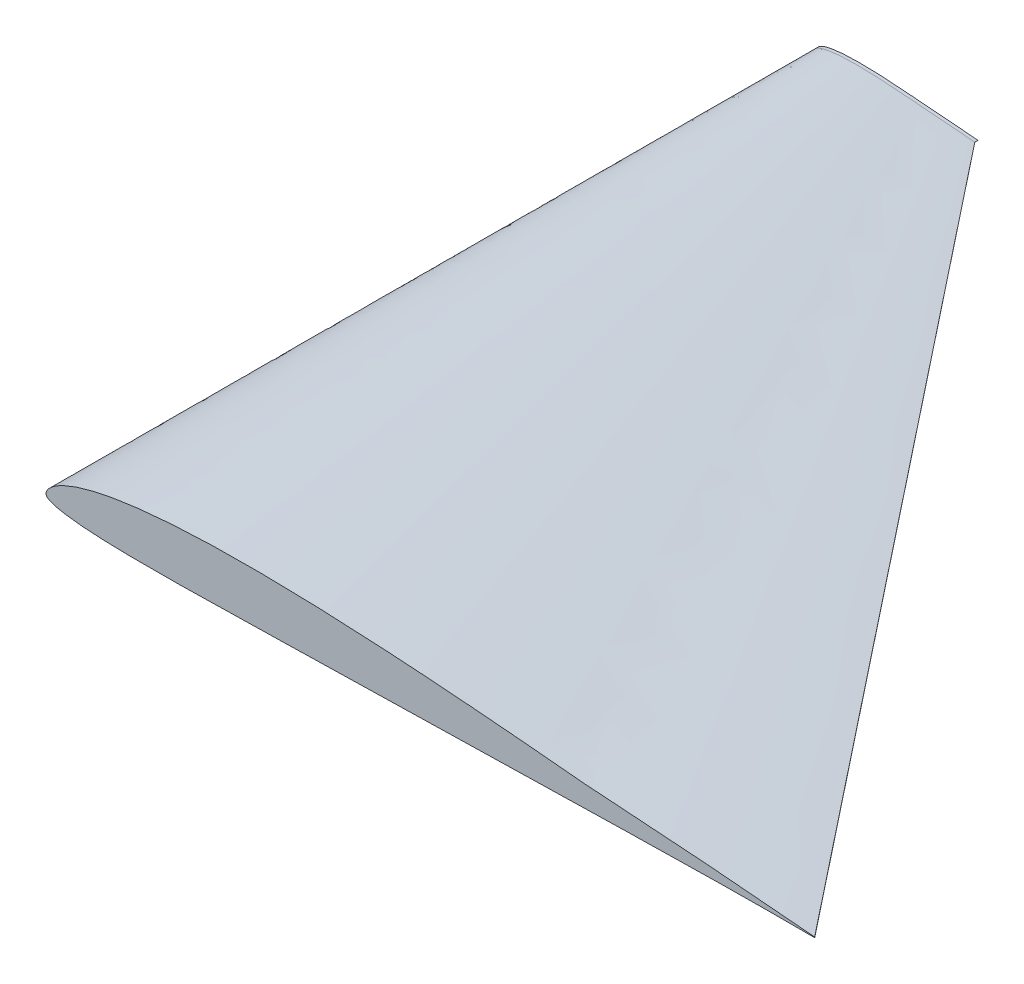
from build123d import *

# Parameters (mm, degrees)
BOSS_EXTRUDE1_DEPTH = 1.27


with BuildPart() as part:
    # Sketch2 → Boss-Extrude1 (new body, symmetric)
    with BuildSketch(Plane.XY):
        with BuildLine():
            Line((127, 0.053594), (127, -0.053594))
            add(Edge.make_bspline(
                [(127, 0.053594), (126.753194187, 0.0760877), (126.00456669, 0.144317059), (124.687918153, 0.26566799), (123.038030908, 0.409881649), (121.307814074, 0.562155781), (119.56263313, 0.715397667), (117.812451704, 0.862564502), (116.060214863, 1.009636724), (114.306556412, 1.15328943), (112.552387701, 1.2954065), (110.798143323, 1.434426003), (109.044365051, 1.569754719), (107.291127286, 1.704537205), (105.538591662, 1.83509141), (103.786392409, 1.964192438), (102.035125629, 2.09083844), (100.284111127, 2.213966217), (98.533897673, 2.336442107), (96.783942419, 2.455531649), (95.034673331, 2.572302888), (93.285592827, 2.687141326), (91.667333214, 2.791597652), (90.409246871, 2.86960854), (89.623239279, 2.921474225), (89.178221792, 2.944143026), (88.736217458, 2.991519492), (87.806500923, 3.077809397), (86.389824841, 3.21548482), (84.900074515, 3.35447567), (83.568446207, 3.477961158), (82.375283312, 3.587920635), (80.880163534, 3.723626147), (79.133561009, 3.880226285), (77.350706131, 4.036649252), (75.57251636, 4.189768369), (73.896258707, 4.331453772), (72.247372758, 4.468190396), (70.810741479, 4.584528401), (69.625039724, 4.678864068), (68.320779781, 4.781533777), (66.809591419, 4.897081839), (65.051660571, 5.027943928), (63.29489006, 5.154836731), (60.953639975, 5.317587866), (58.612649049, 5.470985337), (56.272130878, 5.614205871), (54.517155472, 5.715925242), (52.17781775, 5.84388823), (49.83871845, 5.959559707), (47.499751836, 6.061666427), (45.746142499, 6.131533932), (43.99292996, 6.19316573), (42.240233788, 6.246996168), (40.488296074, 6.292392907), (38.737205548, 6.329056298), (36.986991272, 6.355670586), (35.237667832, 6.37260324), (33.489390788, 6.378111917), (31.742631161, 6.371924362), (29.997598516, 6.353106175), (28.254705362, 6.321034192), (26.514212819, 6.273959582), (24.776789822, 6.210936383), (23.043308585, 6.130697271), (21.314341904, 6.031175464), (19.591301924, 5.911384312), (17.875349563, 5.768217119), (16.168057976, 5.600170111), (14.472222252, 5.403361178), (12.790310639, 5.17550056), (11.127244451, 4.911893185), (9.487723542, 4.607203654), (7.881002216, 4.255424938), (6.321671242, 3.849192622), (4.838377158, 3.3853758), (3.4861692, 2.868431212), (2.344289839, 2.326290026), (1.473834041, 1.805034205), (0.873330801, 1.3482402), (0.483486895, 0.969607531), (0.235533738, 0.65562371), (0.085352034, 0.388606743), (0.009278126, 0.159258483), (-0.008212661, -0.042739441), (0.035433453, -0.233172338), (0.160769969, -0.416078939), (0.381844651, -0.578881525), (0.702443674, -0.744483608), (1.173773308, -0.923146696), (1.873336967, -1.121921903), (2.863352071, -1.325051442), (4.13416469, -1.514401551), (5.608772302, -1.671307235), (7.196892742, -1.792063517), (8.842033522, -1.881526049), (10.518101058, -1.94501169), (12.213760951, -1.988134813), (13.923057968, -2.015603352), (15.642305988, -2.030559213), (17.369324492, -2.03524324), (19.102259281, -2.030376268), (20.840178662, -2.017661001), (22.581905241, -1.998654224), (24.327094149, -1.973870035), (26.075373333, -1.944918864), (27.827248085, -1.912478734), (29.582726999, -1.877605576), (31.342000464, -1.840019272), (33.105065172, -1.801905031), (34.872261178, -1.761818771), (36.643314641, -1.721008732), (39.010854937, -1.665986942), (41.381807413, -1.609827319), (43.75560561, -1.553814319), (45.538561311, -1.511849459), (47.323033301, -1.46955775), (49.109250939, -1.427647022), (50.897446959, -1.385341566), (52.686668924, -1.343543423), (54.475758497, -1.30172749), (56.263619605, -1.260128912), (58.050348911, -1.219185975), (59.835998699, -1.177618913), (61.620483593, -1.137195049), (63.403644196, -1.096671294), (65.185629967, -1.056824853), (66.966841129, -1.016671311), (68.474715573, -0.983169692), (70.232782952, -0.944255707), (71.967211638, -0.905142513), (73.938977171, -0.86146372), (75.655131362, -0.823379675), (77.377116294, -0.784663907), (79.116977386, -0.746124442), (80.674292865, -0.711626582), (82.037721658, -0.681571553), (83.189530456, -0.656499215), (84.514431826, -0.627441819), (86.036149029, -0.594655294), (87.442288836, -0.564185094), (88.395472904, -0.544103578), (88.857745192, -0.53403148), (89.250570862, -0.526534286), (90.047987318, -0.508966656), (91.345085306, -0.481934603), (93.049931567, -0.446327812), (94.810657831, -0.41008595), (96.570459821, -0.374659881), (98.329784851, -0.339179197), (100.089333738, -0.304693935), (101.849164273, -0.270047735), (103.609427245, -0.236629083), (105.36992798, -0.203795698), (107.130919286, -0.174231328), (109.479457843, -0.136894236), (111.828794682, -0.105060522), (114.178357376, -0.07832436), (115.941250848, -0.062296483), (117.704221306, -0.048903014), (119.467622017, -0.040031049), (121.230174814, -0.035574086), (122.981472146, -0.034856596), (124.653848233, -0.041755393), (125.989887143, -0.047834399), (126.749429154, -0.052165261), (127, -0.053594)],
                knots=[0, 0, 0, 0, 0.002900997, 0.008799492, 0.015477521, 0.022287594, 0.029131106, 0.035984573, 0.042846882, 0.049714298, 0.05658103, 0.063447841, 0.070313229, 0.077171168, 0.084031174, 0.090884627, 0.097737396, 0.104584409, 0.111431996, 0.118274877, 0.125116136, 0.131953905, 0.138793041, 0.144098463, 0.146708547, 0.148014316, 0.149313147, 0.151910856, 0.158944662, 0.165973894, 0.169425198, 0.174599098, 0.179999827, 0.186998484, 0.195126222, 0.200949457, 0.207890371, 0.214817866, 0.220316978, 0.224762114, 0.228741132, 0.235631413, 0.242503169, 0.249375779, 0.256249105, 0.269975124, 0.276837254, 0.283697593, 0.290552693, 0.304261607, 0.311111523, 0.317957829, 0.324804965, 0.331646618, 0.338483878, 0.345319338, 0.352148661, 0.358973535, 0.365797142, 0.372613328, 0.379420455, 0.386224885, 0.393018255, 0.399801226, 0.406575621, 0.413331117, 0.420072962, 0.426793048, 0.433486562, 0.440153627, 0.446776036, 0.453352888, 0.45986197, 0.466293612, 0.472602109, 0.478718386, 0.484476601, 0.489534097, 0.493495639, 0.496331131, 0.498346313, 0.499841011, 0.500999224, 0.501914653, 0.502649229, 0.503345398, 0.504157805, 0.50518516, 0.50652574, 0.508375842, 0.511073875, 0.515031357, 0.520196697, 0.526108615, 0.532386125, 0.538838474, 0.545393385, 0.552018993, 0.558693317, 0.565404176, 0.572144526, 0.578909155, 0.585689295, 0.592488493, 0.599298368, 0.606119897, 0.612956027, 0.619808707, 0.626672964, 0.633554162, 0.640451345, 0.647364459, 0.654290996, 0.668172424, 0.675125782, 0.68208558, 0.689048858, 0.69602005, 0.703000172, 0.70998671, 0.716969769, 0.723948347, 0.730920449, 0.737890086, 0.744856199, 0.751814362, 0.758768528, 0.765720713, 0.772669892, 0.776423534, 0.786305074, 0.792977667, 0.799509992, 0.806398719, 0.813139713, 0.819881191, 0.82463258, 0.829103409, 0.833367055, 0.84014514, 0.846920231, 0.849830697, 0.851305256, 0.85233271, 0.85442981, 0.86064179, 0.867519383, 0.874390494, 0.8812566, 0.888123181, 0.894988723, 0.901857217, 0.908727131, 0.915597457, 0.922468599, 0.929343575, 0.943092095, 0.949971604, 0.956848493, 0.963728748, 0.970608901, 0.977490477, 0.984360632, 0.991108924, 0.997066858, 1, 1, 1, 1], degree=3))
        make_face()
    extrude(amount=BOSS_EXTRUDE1_DEPTH, both=True)

    # Sketch3 → section 1 of loft4
    with BuildSketch(Plane.XY.offset(610.87), mode=Mode.PRIVATE) as loft4_s1:
        with BuildLine():
            Line((609.6, 0.2572512), (609.6, -0.2572512))
            add(Edge.make_bspline(
                [(609.6, 0.2572512), (608.415332097, 0.365220961), (604.821920112, 0.692721884), (598.502007136, 1.275206353), (590.58254836, 1.967431913), (582.277507556, 2.69834775), (573.900639024, 3.433908802), (565.499768181, 4.14030961), (557.08903134, 4.846256275), (548.671470775, 5.535789265), (540.251460963, 6.217951202), (531.831087952, 6.885244816), (523.412952246, 7.534822651), (514.997410973, 8.181778582), (506.585239979, 8.808438766), (498.174683562, 9.428123701), (489.768603017, 10.036024513), (481.363733408, 10.627037843), (472.962708832, 11.214922115), (464.562923613, 11.786551917), (456.166431988, 12.347053861), (447.770845571, 12.898278365), (440.003199426, 13.399668731), (433.96438498, 13.774120994), (430.191548537, 14.023076282), (428.055464604, 14.131886527), (425.933843798, 14.359293563), (421.47120443, 14.773485107), (414.671159239, 15.434327135), (407.520357673, 16.101483217), (401.128541792, 16.694213561), (395.401359899, 17.22201905), (388.224784964, 17.873405506), (379.841092841, 18.625086168), (371.28338943, 19.375916411), (362.748078527, 20.110888169), (354.702041793, 20.790978105), (346.78738924, 21.447313902), (339.891559101, 22.005736324), (334.200190675, 22.458547528), (327.939742949, 22.951362128), (320.686038813, 23.505992825), (312.247970741, 24.134130856), (303.815472288, 24.743216311), (292.577471879, 25.524421758), (281.340715435, 26.260729616), (270.106228216, 26.94818818), (261.682346264, 27.436441163), (250.453525202, 28.050663502), (239.225848559, 28.605886591), (227.998808811, 29.09599885), (219.581483994, 29.431362872), (211.166063809, 29.727195505), (202.753122181, 29.985581608), (194.343821157, 30.203485951), (185.938586629, 30.379470231), (177.537558104, 30.507218814), (169.140805594, 30.588495554), (160.749075784, 30.614937204), (152.364629575, 30.585236939), (143.988472876, 30.494909638), (135.622585739, 30.340964124), (127.268221532, 30.115005994), (118.928591145, 29.812494639), (110.60788121, 29.427346901), (102.308841137, 28.949642229), (94.038249233, 28.3746447), (85.801677902, 27.687442171), (77.606678285, 26.880816531), (69.466666809, 25.936133655), (61.393491068, 24.842402689), (53.410773367, 23.577087289), (45.541073, 22.114577537), (37.828810634, 20.426039702), (30.344021962, 18.476124586), (23.224210357, 16.249803841), (16.73361216, 13.768469819), (11.252591229, 11.166192123), (7.074403395, 8.664164182), (4.191987844, 6.471552962), (2.320737094, 4.654116149), (1.130561945, 3.146993807), (0.409689764, 1.865312365), (0.044535005, 0.764440717), (-0.039420771, -0.205149315), (0.170080572, -1.119227224), (0.77169585, -1.997178905), (1.832854324, -2.778631321), (3.371729637, -3.573521318), (5.634111878, -4.43110414), (8.992017444, -5.385225136), (13.744089942, -6.360246924), (19.84399051, -7.269127446), (26.92210705, -8.022274727), (34.545085162, -8.60190488), (42.441760907, -9.031325034), (50.486885076, -9.336056111), (58.626052563, -9.543047104), (66.830678248, -9.67489609), (75.083068743, -9.746684223), (83.37275756, -9.769167554), (91.690844547, -9.745806087), (100.032857577, -9.684772804), (108.393145156, -9.593540277), (116.770051914, -9.474576166), (125.161791998, -9.335610545), (133.570790806, -9.179897921), (141.997089596, -9.012506765), (150.441602227, -8.832092507), (158.904312825, -8.64914415), (167.386853653, -8.456730101), (175.887910278, -8.260841912), (187.252103698, -7.996737324), (198.632675581, -7.727171132), (210.026906928, -7.45830873), (218.585094291, -7.256877402), (227.150559846, -7.053877202), (235.724404509, -6.852705707), (244.307745405, -6.649639518), (252.896010837, -6.449008432), (261.483640787, -6.24829195), (270.065374104, -6.048618778), (278.641674775, -5.85209268), (287.212793757, -5.65257078), (295.778321245, -5.458536237), (304.337492142, -5.264022213), (312.891023844, -5.072759296), (321.44083742, -4.880022295), (328.678634748, -4.71921452), (337.117358168, -4.532427393), (345.442615864, -4.344684062), (354.907090423, -4.135025854), (363.144630539, -3.952222438), (371.410158212, -3.766386754), (379.761491454, -3.581397323), (387.236605751, -3.415807595), (393.781063961, -3.271543457), (399.309746187, -3.151196232), (405.669272764, -3.011720732), (412.973515337, -2.854345409), (419.722986413, -2.708088451), (424.298269937, -2.611697174), (426.517176923, -2.563351102), (428.402740136, -2.527364572), (432.230339127, -2.443039947), (438.456409466, -2.313286096), (446.639671523, -2.142373496), (455.091157591, -1.96841256), (463.538207143, -1.798367427), (471.982967287, -1.628060144), (480.428801943, -1.462530887), (488.87598851, -1.296229127), (497.325250778, -1.135819597), (505.775654302, -0.97821935), (514.228412573, -0.836310375), (525.501397646, -0.657092333), (536.778214476, -0.504290503), (548.056115404, -0.375956926), (556.518004069, -0.29902312), (564.980262271, -0.234734468), (573.44458568, -0.192149035), (581.904839109, -0.170755614), (590.311066301, -0.167311659), (598.338471518, -0.200425886), (604.751458285, -0.229605115), (608.397259937, -0.250393251), (609.6, -0.2572512)],
                knots=[0, 0, 0, 0, 0.002900997, 0.008799492, 0.015477521, 0.022287594, 0.029131106, 0.035984573, 0.042846882, 0.049714298, 0.05658103, 0.063447841, 0.070313229, 0.077171168, 0.084031174, 0.090884627, 0.097737396, 0.104584409, 0.111431996, 0.118274877, 0.125116136, 0.131953905, 0.138793041, 0.144098463, 0.146708547, 0.148014316, 0.149313147, 0.151910856, 0.158944662, 0.165973894, 0.169425198, 0.174599098, 0.179999827, 0.186998484, 0.195126222, 0.200949457, 0.207890371, 0.214817866, 0.220316978, 0.224762114, 0.228741132, 0.235631413, 0.242503169, 0.249375779, 0.256249105, 0.269975124, 0.276837254, 0.283697593, 0.290552693, 0.304261607, 0.311111523, 0.317957829, 0.324804965, 0.331646618, 0.338483878, 0.345319338, 0.352148661, 0.358973535, 0.365797142, 0.372613328, 0.379420455, 0.386224885, 0.393018255, 0.399801226, 0.406575621, 0.413331117, 0.420072962, 0.426793048, 0.433486562, 0.440153627, 0.446776036, 0.453352888, 0.45986197, 0.466293612, 0.472602109, 0.478718386, 0.484476601, 0.489534097, 0.493495639, 0.496331131, 0.498346313, 0.499841011, 0.500999224, 0.501914653, 0.502649229, 0.503345398, 0.504157805, 0.50518516, 0.50652574, 0.508375842, 0.511073875, 0.515031357, 0.520196697, 0.526108615, 0.532386125, 0.538838474, 0.545393385, 0.552018993, 0.558693317, 0.565404176, 0.572144526, 0.578909155, 0.585689295, 0.592488493, 0.599298368, 0.606119897, 0.612956027, 0.619808707, 0.626672964, 0.633554162, 0.640451345, 0.647364459, 0.654290996, 0.668172424, 0.675125782, 0.68208558, 0.689048858, 0.69602005, 0.703000172, 0.70998671, 0.716969769, 0.723948347, 0.730920449, 0.737890086, 0.744856199, 0.751814362, 0.758768528, 0.765720713, 0.772669892, 0.776423534, 0.786305074, 0.792977667, 0.799509992, 0.806398719, 0.813139713, 0.819881191, 0.82463258, 0.829103409, 0.833367055, 0.84014514, 0.846920231, 0.849830697, 0.851305256, 0.85233271, 0.85442981, 0.86064179, 0.867519383, 0.874390494, 0.8812566, 0.888123181, 0.894988723, 0.901857217, 0.908727131, 0.915597457, 0.922468599, 0.929343575, 0.943092095, 0.949971604, 0.956848493, 0.963728748, 0.970608901, 0.977490477, 0.984360632, 0.991108924, 0.997066858, 1, 1, 1, 1], degree=3))
        make_face()
    # loft from a face of the part (loft4)
    loft([part.faces().sort_by_distance((51.985941345, 1.506052902, 1.27))[0], loft4_s1.sketch])


solid = part.part
